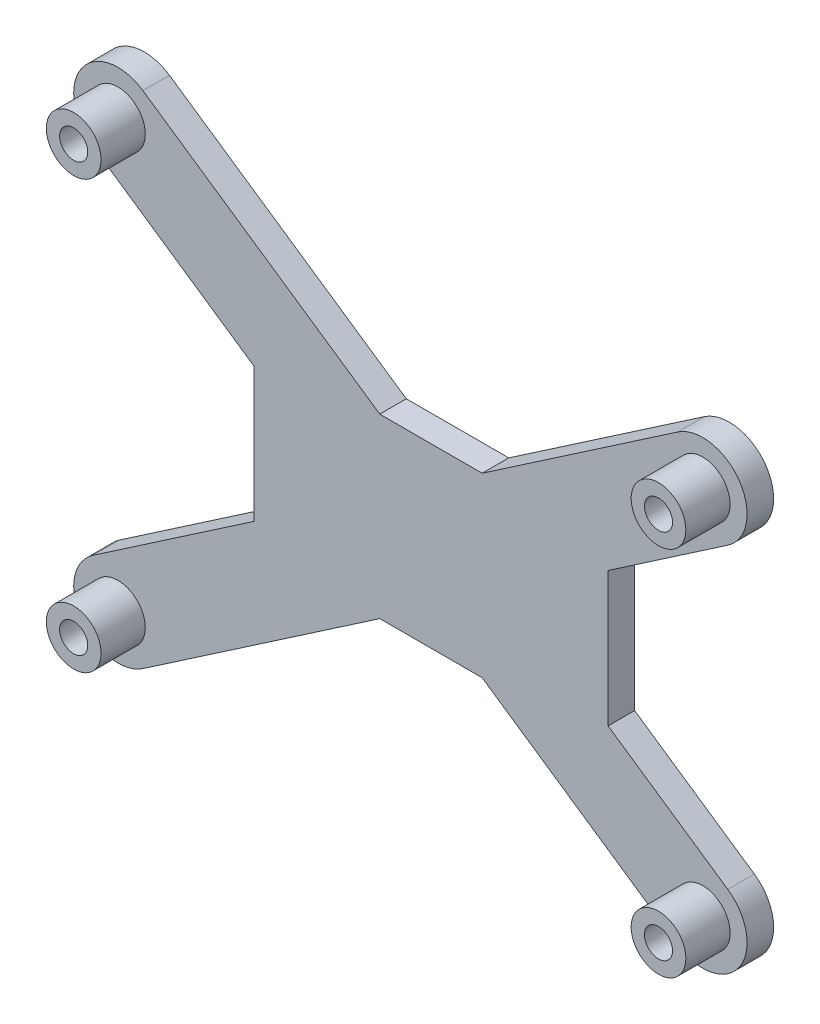
from build123d import *

# Parameters (mm, degrees)
SKETCH4_R             = 3.0875
SKETCH4_R_2           = 1.5875
BOSS_EXTRUDE1_DEPTH   = 5
BOSS_EXTRUDE1_2_DEPTH = 5
BOSS_EXTRUDE1_3_DEPTH = 5
BOSS_EXTRUDE1_4_DEPTH = 5
COMBINATION_R         = 1.5875
BOSS_EXTRUDE2_DEPTH   = 3


with BuildPart() as part:
    # Sketch4 → Boss-Extrude1 (new body)
    with BuildSketch(Plane.XY):
        with Locations((14.605, 3.175)):
            Circle(SKETCH4_R)
        with Locations((14.605, 3.175)):
            Circle(SKETCH4_R_2, mode=Mode.SUBTRACT)
    extrude(amount=BOSS_EXTRUDE1_DEPTH)



with BuildPart() as body_2:
    # Sketch4 → Boss-Extrude1 2 (new body)
    with BuildSketch(Plane.XY):
        with Locations((14.605, 51.435)):
            Circle(SKETCH4_R)
        with Locations((14.605, 51.435)):
            Circle(SKETCH4_R_2, mode=Mode.SUBTRACT)
    extrude(amount=BOSS_EXTRUDE1_2_DEPTH)


with BuildPart() as body_3:
    # Sketch4 → Boss-Extrude1 3 (new body)
    with BuildSketch(Plane.XY):
        with Locations((80.645, 48.26)):
            Circle(SKETCH4_R)
        with Locations((80.645, 48.26)):
            Circle(SKETCH4_R_2, mode=Mode.SUBTRACT)
    extrude(amount=BOSS_EXTRUDE1_3_DEPTH)


with BuildPart() as body_4:
    # Sketch4 → Boss-Extrude1 4 (new body)
    with BuildSketch(Plane.XY):
        with Locations((80.645, 6.35)):
            Circle(SKETCH4_R)
        with Locations((80.645, 6.35)):
            Circle(SKETCH4_R_2, mode=Mode.SUBTRACT)
    extrude(amount=BOSS_EXTRUDE1_4_DEPTH)


with BuildPart() as part_1:
    add(part.part)

    add(body_2.part)  # Boss-Extrude2 merges body 2

    add(body_3.part)  # Boss-Extrude2 merges body 3

    add(body_4.part)  # Boss-Extrude2 merges body 4
    # combination → Boss-Extrude2 (add)
    with BuildSketch(Plane.XY):
        with BuildLine():
            Line((17.424147765, 55.564455882), (44.170393, 37.305))
            Line((44.170393, 37.305), (49.950352113, 37.305))
            Line((49.950352113, 37.305), (55.730311225, 37.305))
            Line((55.730311225, 37.305), (77.825852235, 52.389455882))
            ThreePointArc((77.825852235, 52.389455882), (84.774455882, 51.079147765), (83.464147765, 44.130544118))
            Line((83.464147765, 44.130544118), (69.950352113, 34.904779779))
            Line((69.950352113, 34.904779779), (69.950352113, 19.705220221))
            Line((69.950352113, 19.705220221), (83.464147765, 10.479455882))
            ThreePointArc((83.464147765, 10.479455882), (84.774455882, 3.530852235), (77.825852235, 2.220544118))
            Line((77.825852235, 2.220544118), (55.730311225, 17.305))
            Line((55.730311225, 17.305), (49.950352113, 17.305))
            Line((49.950352113, 17.305), (44.170393, 17.305))
            Line((44.170393, 17.305), (17.424147765, -0.954455882))
            ThreePointArc((17.424147765, -0.954455882), (10.475544118, 0.355852235), (11.785852235, 7.304455882))
            Line((11.785852235, 7.304455882), (29.950352113, 19.705220221))
            Line((29.950352113, 19.705220221), (29.950352113, 34.904779779))
            Line((29.950352113, 34.904779779), (11.785852235, 47.305544118))
            ThreePointArc((11.785852235, 47.305544118), (10.475544118, 54.254147765), (17.424147765, 55.564455882))
        make_face()
        with Locations((14.605, 51.435)):
            Circle(COMBINATION_R, mode=Mode.SUBTRACT)
        with Locations((14.605, 3.175)):
            Circle(COMBINATION_R, mode=Mode.SUBTRACT)
        with Locations((80.645, 6.35)):
            Circle(COMBINATION_R, mode=Mode.SUBTRACT)
        with Locations((80.645, 48.26)):
            Circle(COMBINATION_R, mode=Mode.SUBTRACT)
    extrude(amount=-BOSS_EXTRUDE2_DEPTH)


solid = part_1.part
